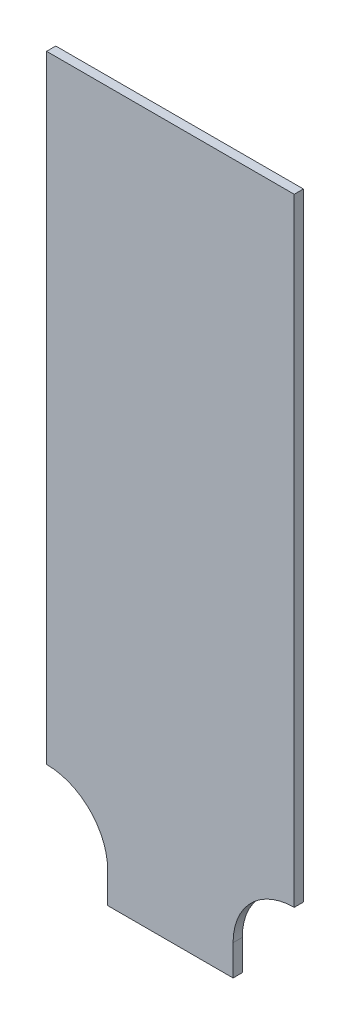
from build123d import *

# Parameters (mm, degrees)
EXTRUSION1_DEPTH = 3


with BuildPart() as part:
    # Esquisse1 → Extrusion1 (new body)
    with BuildSketch(Plane.XY):
        with BuildLine():
            Line((40.5, 232), (-40.5, 232))
            Line((-40.5, 232), (-40.5, 30))
            ThreePointArc((-40.5, 30), (-26.357864376, 24.142135624), (-20.5, 10))
            Line((-20.5, 10), (-20.5, 0))
            Line((-20.5, 0), (20.5, 0))
            Line((20.5, 0), (20.5, 10))
            ThreePointArc((20.5, 10), (26.357864376, 24.142135624), (40.5, 30))
            Line((40.5, 30), (40.5, 232))
        make_face()
    extrude(amount=EXTRUSION1_DEPTH)


solid = part.part
